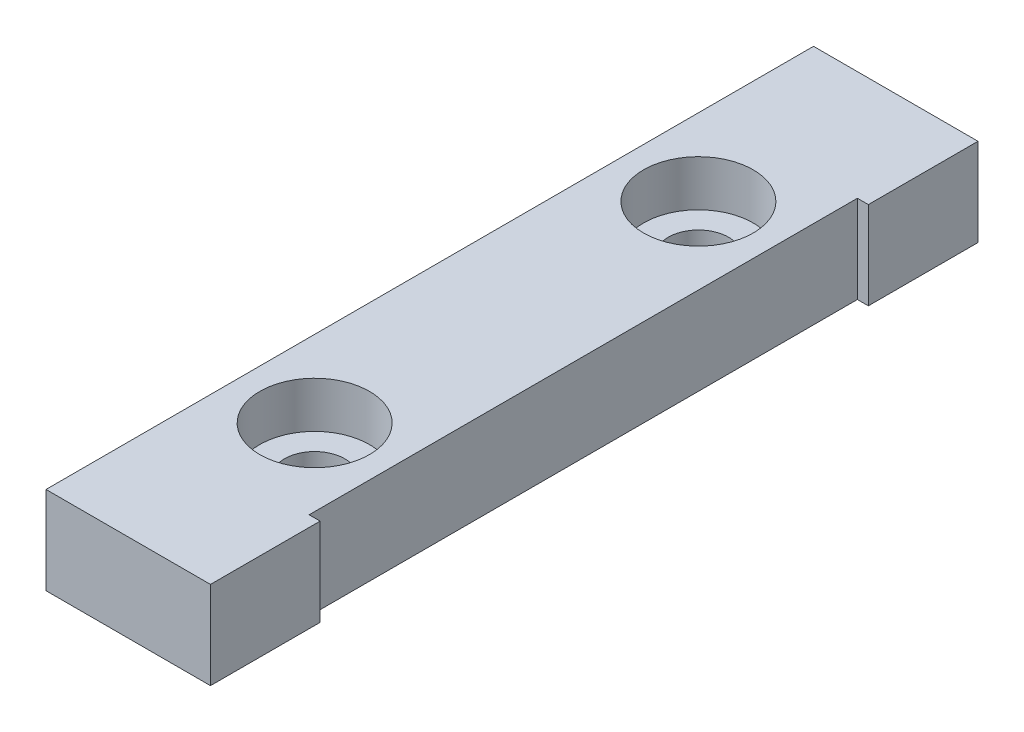
from build123d import *

# Parameters (mm, degrees)
BOSS_EXTRUDE1_DEPTH = 8
SKETCH2_R           = 2.75
CUT_EXTRUDE1_DEPTH  = 9
SKETCH3_R           = 5
CUT_EXTRUDE2_DEPTH  = 4.2


with BuildPart() as part:
    # Sketch1 → Boss-Extrude1 (new body)
    with BuildSketch(Plane(origin=(0, 0, 0), x_dir=(1, 0, 0), z_dir=(0, 1, 0))):
        Polygon((7.5, 25), (6.5, 25), (6.5, -25), (7.5, -25), (7.5, -35), (-7.5, -35), (-7.5, 35), (7.5, 35), align=None)
    extrude(amount=BOSS_EXTRUDE1_DEPTH)

    # Sketch2 → Cut-Extrude1 (cut, through all)
    with BuildSketch(Plane(origin=(0, 8, 0), x_dir=(1, 0, 0), z_dir=(0, 1, 0))):
        with Locations((-0.5, 17.5)):
            Circle(SKETCH2_R)
        with Locations((-0.5, -17.5)):
            Circle(SKETCH2_R)
    extrude(amount=-CUT_EXTRUDE1_DEPTH, mode=Mode.SUBTRACT)

    # Sketch3 → Cut-Extrude2 (cut)
    with BuildSketch(Plane(origin=(0, 8, 0), x_dir=(1, 0, 0), z_dir=(0, 1, 0))):
        with Locations((-0.5, 17.5)):
            Circle(SKETCH3_R)
        with Locations((-0.5, -17.5)):
            Circle(SKETCH3_R)
    extrude(amount=-CUT_EXTRUDE2_DEPTH, mode=Mode.SUBTRACT)


solid = part.part
